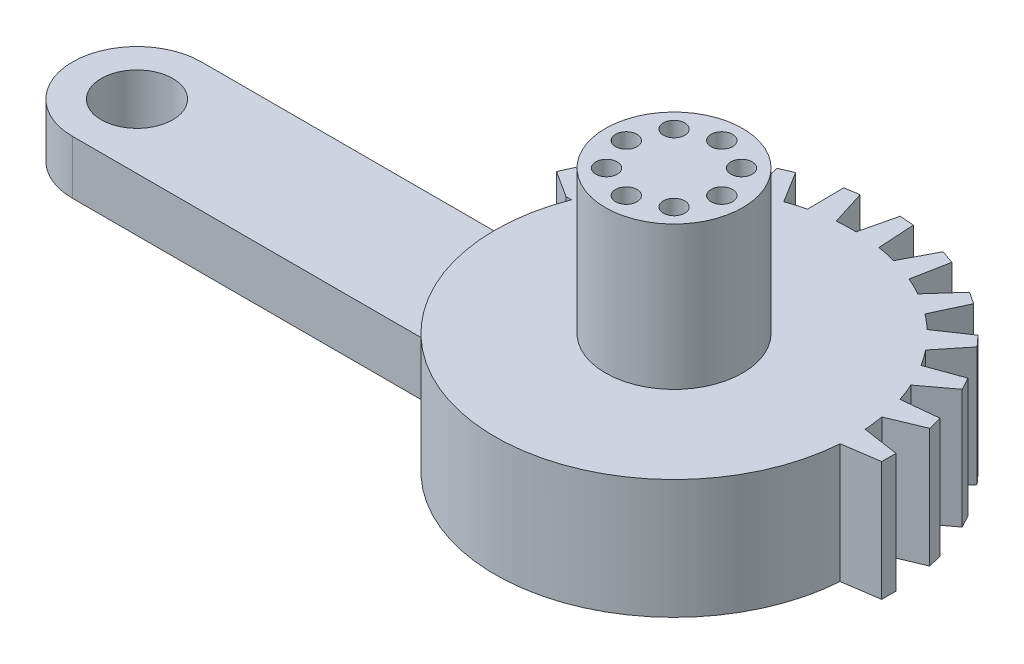
from build123d import *

# Parameters (mm, degrees)
BOSS_EXTRUDE1_DEPTH = 33.333333333
BOSS_EXTRUDE2_DEPTH = 33.333333333
CIRPATTERN2_COUNT   = 13
CIRPATTERN2_ANGLE   = 170
F_20_0MM_1_D        = 20
SCALE_1_SCALE       = 0.3
CUT_EXTRUDE_1_DEPTH = 5.5
SKETCH_2_R          = 5.75
EXTRUDE_1_DEPTH     = 12
SKETCH_3_R          = 0.9
CUT_EXTRUDE_2_DEPTH = 7


with BuildPart() as part:
    # Sketch1 → Boss-Extrude1 (new body)
    with BuildSketch(Plane(origin=(0, 0, 0), x_dir=(1, 0, 0), z_dir=(0, 1, 0))):
        with BuildLine():
            Line((-150, 18), (-46.647615159, 18))
            ThreePointArc((-46.647615159, 18), (50, 0), (-46.647615159, -18))
            Line((-46.647615159, -18), (-150, -18))
            ThreePointArc((-150, -18), (-168, 0), (-150, 18))
        make_face()
    extrude(amount=BOSS_EXTRUDE1_DEPTH)

    # Sketch2 → Boss-Extrude2 (add)
    with BuildSketch(Plane(origin=(0, 33.333333333, 0), x_dir=(1, 0, 0), z_dir=(0, 1, 0))):
        Polygon((49.877349569, 3.5), (60, 2), (60, -2), (49.877349569, -3.5), (50, 0), align=None)
    boss_extrude2 = extrude(amount=-BOSS_EXTRUDE2_DEPTH)

    # CirPattern2: Boss-Extrude2 ×13 about axis
    cirpattern2_axis = Axis((0, 0, 0), (0, 1, 0))
    for i in range(1, CIRPATTERN2_COUNT):
        add(boss_extrude2.rotate(cirpattern2_axis, i * CIRPATTERN2_ANGLE / (CIRPATTERN2_COUNT - 1)))

    # Ø20.0mm 맞춤핀 구멍1 (through all)
    with Locations(Plane(origin=(0, 33.333333333, 0), x_dir=(1, 0, 0), z_dir=(0, 1, 0))):
        with Locations((-150, 0)):
            Hole(F_20_0MM_1_D / 2)


with BuildPart() as part_1:
    # 축척1: scaled about (-31.576481157, 16.666666667, -1.921113945)
    add(part.part.scale(SCALE_1_SCALE).moved(Location((-22.10353681, 11.666666667, -1.344779761))))

    # 스케치1 → 컷-돌출1 (cut)
    with BuildSketch(Plane(origin=(0, 21.666666667, 0), x_dir=(1, 0, 0), z_dir=(0, 1, 0))):
        with BuildLine():
            Line((-36.097821358, -4.055220239), (-67.10353681, -4.055220239))
            ThreePointArc((-67.10353681, -4.055220239), (-72.50353681, 1.344779761), (-67.10353681, 6.744779761))
            Line((-67.10353681, 6.744779761), (-36.097821358, 6.744779761))
            ThreePointArc((-36.097821358, 6.744779761), (-37.10353681, 1.344779761), (-36.097821358, -4.055220239))
        make_face()
    extrude(amount=-CUT_EXTRUDE_1_DEPTH, mode=Mode.SUBTRACT)

    # 스케치2 → 보스-돌출1 (add)
    with BuildSketch(Plane(origin=(0, 21.666666667, 0), x_dir=(1, 0, 0), z_dir=(0, 1, 0))):
        with Locations(Location((-22.10353681, 1.344779761, 0), (0, 0, 270))):
            Circle(SKETCH_2_R)
    extrude(amount=EXTRUDE_1_DEPTH)

    # 스케치3 → 컷-돌출2 (cut)
    with BuildSketch(Plane(origin=(0, 33.666666667, 0), x_dir=(1, 0, 0), z_dir=(0, 1, 0))):
        with Locations(Location((-22.10353681, -2.655220239, 0), (0, 0, 270))):
            Circle(SKETCH_3_R)
        with Locations(Location((-19.275109685, -1.483647363, 0), (0, 0, 270))):
            Circle(SKETCH_3_R)
        with Locations(Location((-18.10353681, 1.344779761, 0), (0, 0, 270))):
            Circle(SKETCH_3_R)
        with Locations(Location((-24.931963935, -1.483647363, 0), (0, 0, 90))):
            Circle(SKETCH_3_R)
        with Locations(Location((-26.10353681, 1.344779761, 0), (0, 0, 90))):
            Circle(SKETCH_3_R)
        with Locations(Location((-24.931963935, 4.173206886, 0), (0, 0, 270))):
            Circle(SKETCH_3_R)
        with Locations(Location((-22.10353681, 5.344779761, 0), (0, 0, 90))):
            Circle(SKETCH_3_R)
        with Locations(Location((-19.275109685, 4.173206886, 0), (0, 0, 90))):
            Circle(SKETCH_3_R)
    extrude(amount=-CUT_EXTRUDE_2_DEPTH, mode=Mode.SUBTRACT)


solid = part_1.part
